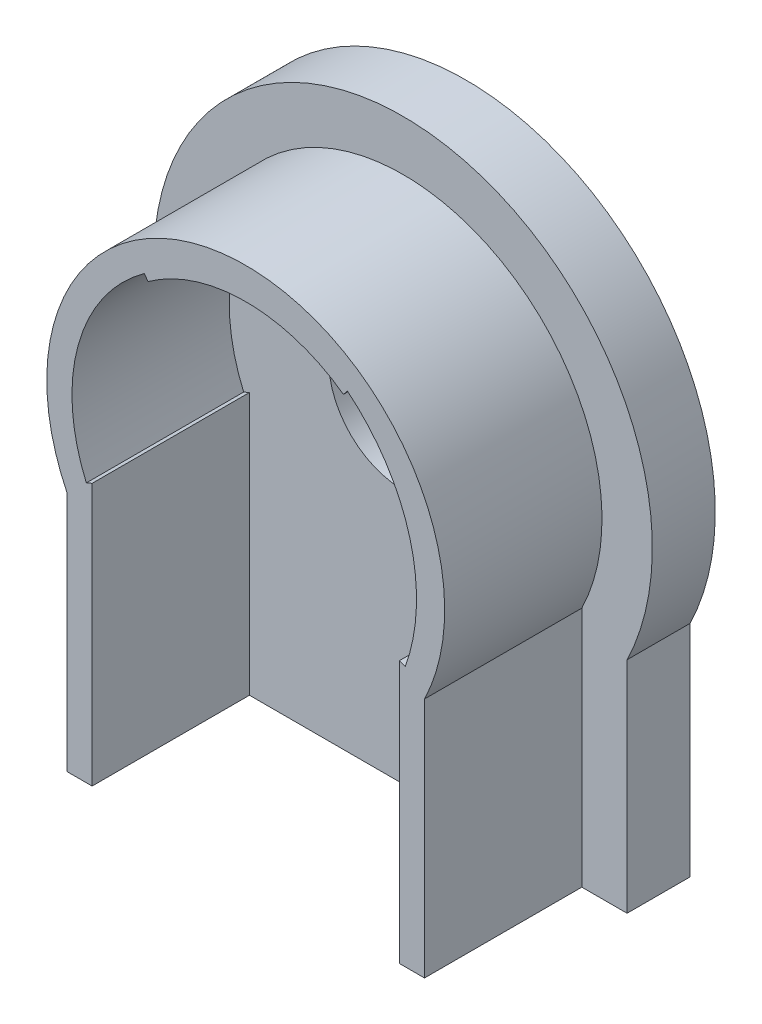
from build123d import *

# Parameters (mm, degrees)
SALIENTE_EXTRUIR1_DEPTH = 7.9375
CROQUIS4_R              = 3.75
SALIENTE_EXTRUIR5_DEPTH = 3.175
CORTAR_EXTRUIR2_DEPTH   = 7.9375
CORTAR_EXTRUIR1_DEPTH   = 1.7145


with BuildPart() as part:
    # Croquis1 → Saliente-Extruir1 (new body)
    with BuildSketch(Plane.XY):
        with BuildLine():
            Line((9.02, -8.199999983), (9.02, -4.401948997))
            ThreePointArc((9.02, -4.401948997), (0, 10.03681), (-9.02, -4.401948997))
            Line((-9.02, -4.401948997), (-9.02, -8.465948997))
            Line((-9.02, -8.465948997), (-9.02, -16.593948997))
            Line((-9.02, -16.593948997), (-7.75, -16.593948997))
            Line((-7.75, -16.593948997), (-7.75, -8.465948997))
            Line((-7.75, -8.465948997), (-7.75, -3.365759866))
            ThreePointArc((-7.75, -3.365759866), (0, 8.44931), (7.75, -3.365759866))
            Line((7.75, -3.365759866), (7.75, -8.199999983))
            Line((7.75, -8.199999983), (7.75, -16.593948997))
            Line((7.75, -16.593948997), (9.02, -16.593948997))
            Line((9.02, -16.593948997), (9.02, -8.199999983))
        make_face()
    extrude(amount=SALIENTE_EXTRUIR1_DEPTH)

    # Croquis4 → Saliente-Extruir5 (add)
    with BuildSketch(Plane.XY):
        with BuildLine():
            Line((-11.302677464, -5.515943429), (-11.302677464, -16.593948997))
            Line((-11.302677464, -16.593948997), (-9.02, -16.593948997))
            Line((-9.02, -16.593948997), (9.02, -16.593948997))
            Line((9.02, -16.593948997), (11.302677464, -16.593948997))
            Line((11.302677464, -16.593948997), (11.302677464, -5.515943429))
            ThreePointArc((11.302677464, -5.515943429), (0, 12.57681), (-11.302677464, -5.515943429))
        make_face()
        Circle(CROQUIS4_R, mode=Mode.SUBTRACT)
    extrude(amount=-SALIENTE_EXTRUIR5_DEPTH)

    # Croquis6 → Cortar-Extruir2 (cut)
    with BuildSketch(Plane.XY.offset(7.9375)):
        with BuildLine():
            Line((-8.041222005, -3.492235135), (-7.75, -3.365759866))
            ThreePointArc((-7.75, -3.365759866), (-8.145389049, 2.245768624), (-4.930152432, 6.86181))
            Line((-4.930152432, 6.86181), (-5.115412932, 7.11965646))
            ThreePointArc((-5.115412932, 7.11965646), (-8.451468602, 2.330157945), (-8.041222005, -3.492235135))
        make_face()
        with BuildLine():
            Line((7.75, -3.365759866), (8.048475458, -3.474012585))
            ThreePointArc((8.048475458, -3.474012585), (8.275668302, 2.281687971), (5.130979952, 7.107725752))
            Line((5.130979952, 7.107725752), (4.930152432, 6.86181))
            ThreePointArc((4.930152432, 6.86181), (7.96958875, 2.19729865), (7.75, -3.365759866))
        make_face()
    extrude(amount=-CORTAR_EXTRUIR2_DEPTH, mode=Mode.SUBTRACT)

    # Croquis5 → Cortar-Extruir1 (cut)
    with BuildSketch(Plane.XY):
        with BuildLine():
            Line((6.854573627, -3.041001708), (8.048475458, -3.474012585))
            ThreePointArc((8.048475458, -3.474012585), (8.609503442, -0.613823624), (8.275668302, 2.281687971))
            Line((8.275668302, 2.281687971), (7.051350093, 1.944130685))
            ThreePointArc((7.051350093, 1.944130685), (7.340491675, -0.563732346), (6.854573627, -3.041001708))
        make_face()
    extrude(amount=-CORTAR_EXTRUIR1_DEPTH, mode=Mode.SUBTRACT)


solid = part.part
